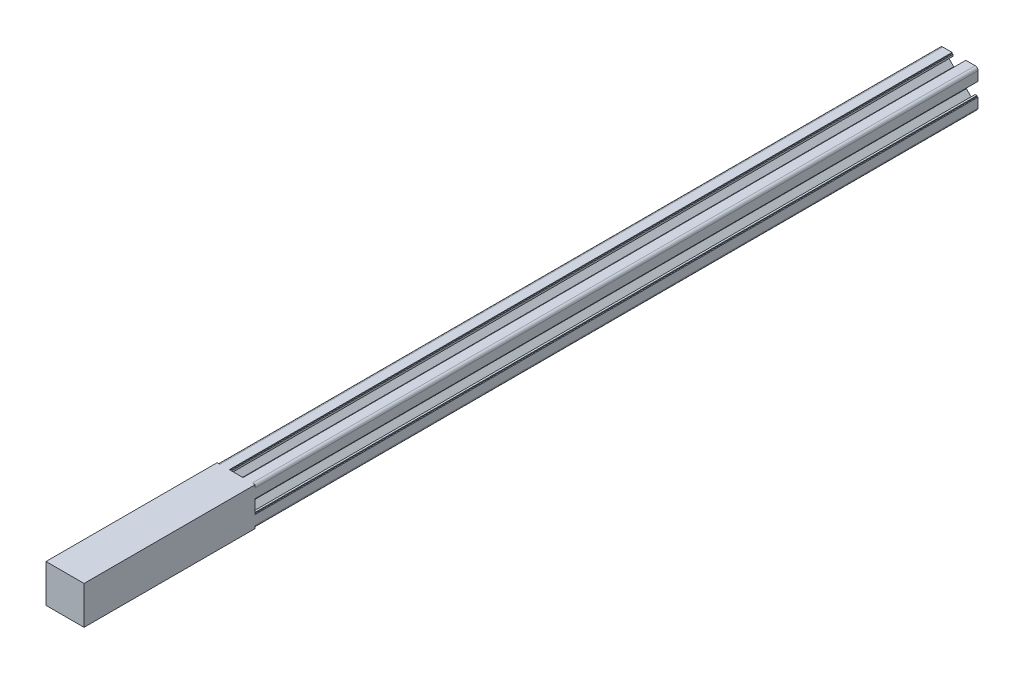
from build123d import *

# Parameters (mm, degrees)
SKETCH_1_R      = 2.5
EXTRUDE_1_DEPTH = 380
EXTRUDE_2_DEPTH = 90


with BuildPart() as part:
    # 草图1 → 凸台-拉伸1 (new body)
    with BuildSketch(Plane.XY):
        with BuildLine():
            Line((-3.6, 10), (-3.6, 9.5))
            Line((-3.6, 9.5), (-3.1, 9.5))
            Line((-3.1, 9.5), (-3.1, 8.5))
            Line((-3.1, 8.5), (-5.5, 8.5))
            Line((-5.5, 8.5), (-5.5, 6.65))
            Line((-5.5, 6.65), (-2.75, 3.9))
            Line((-2.75, 3.9), (2.75, 3.9))
            Line((2.75, 3.9), (5.5, 6.65))
            Line((5.5, 6.65), (5.5, 8.5))
            Line((5.5, 8.5), (3.1, 8.5))
            Line((3.1, 8.5), (3.1, 9.5))
            Line((3.1, 9.5), (3.6, 9.5))
            Line((3.6, 9.5), (3.6, 10))
            Line((3.6, 10), (8.5, 10))
            ThreePointArc((8.5, 10), (9.560660172, 9.560660172), (10, 8.5))
            Line((10, 8.5), (10, 3.6))
            Line((10, 3.6), (9.5, 3.6))
            Line((9.5, 3.6), (9.5, 3.1))
            Line((9.5, 3.1), (8.5, 3.1))
            Line((8.5, 3.1), (8.5, 5.5))
            Line((8.5, 5.5), (6.65, 5.5))
            Line((6.65, 5.5), (3.9, 2.75))
            Line((3.9, 2.75), (3.9, -2.75))
            Line((3.9, -2.75), (6.65, -5.5))
            Line((6.65, -5.5), (8.5, -5.5))
            Line((8.5, -5.5), (8.5, -3.1))
            Line((8.5, -3.1), (9.5, -3.1))
            Line((9.5, -3.1), (9.5, -3.6))
            Line((9.5, -3.6), (10, -3.6))
            Line((10, -3.6), (10, -8.5))
            ThreePointArc((10, -8.5), (9.560660172, -9.560660172), (8.5, -10))
            Line((8.5, -10), (3.6, -10))
            Line((3.6, -10), (3.6, -9.5))
            Line((3.6, -9.5), (3.1, -9.5))
            Line((3.1, -9.5), (3.1, -8.5))
            Line((3.1, -8.5), (5.5, -8.5))
            Line((5.5, -8.5), (5.5, -6.65))
            Line((5.5, -6.65), (2.75, -3.9))
            Line((2.75, -3.9), (-2.75, -3.9))
            Line((-2.75, -3.9), (-5.5, -6.65))
            Line((-5.5, -6.65), (-5.5, -8.5))
            Line((-5.5, -8.5), (-3.1, -8.5))
            Line((-3.1, -8.5), (-3.1, -9.5))
            Line((-3.1, -9.5), (-3.6, -9.5))
            Line((-3.6, -9.5), (-3.6, -10))
            Line((-3.6, -10), (-8.5, -10))
            ThreePointArc((-8.5, -10), (-9.560660172, -9.560660172), (-10, -8.5))
            Line((-10, -8.5), (-10, -3.6))
            Line((-10, -3.6), (-9.5, -3.6))
            Line((-9.5, -3.6), (-9.5, -3.1))
            Line((-9.5, -3.1), (-8.5, -3.1))
            Line((-8.5, -3.1), (-8.5, -5.5))
            Line((-8.5, -5.5), (-6.65, -5.5))
            Line((-6.65, -5.5), (-3.9, -2.75))
            Line((-3.9, -2.75), (-3.9, 2.75))
            Line((-3.9, 2.75), (-6.65, 5.5))
            Line((-6.65, 5.5), (-8.5, 5.5))
            Line((-8.5, 5.5), (-8.5, 3.1))
            Line((-8.5, 3.1), (-9.5, 3.1))
            Line((-9.5, 3.1), (-9.5, 3.6))
            Line((-9.5, 3.6), (-10, 3.6))
            Line((-10, 3.6), (-10, 8.5))
            ThreePointArc((-10, 8.5), (-9.560660172, 9.560660172), (-8.5, 10))
            Line((-8.5, 10), (-3.6, 10))
        make_face()
        Circle(SKETCH_1_R, mode=Mode.SUBTRACT)
    extrude(amount=EXTRUDE_1_DEPTH)

    # 草图2 → 凸台-拉伸2 (add)
    with BuildSketch(Plane.XY.offset(380)):
        Polygon((8.5, 10), (-8.5, 10), (-10, 10), (-10, 8.5), (-10, -8.5), (-10, -10), (-8.5, -10), (8.5, -10), (10, -10), (10, -8.5), (10, 8.5), (10, 10), align=None)
    extrude(amount=EXTRUDE_2_DEPTH)


solid = part.part
